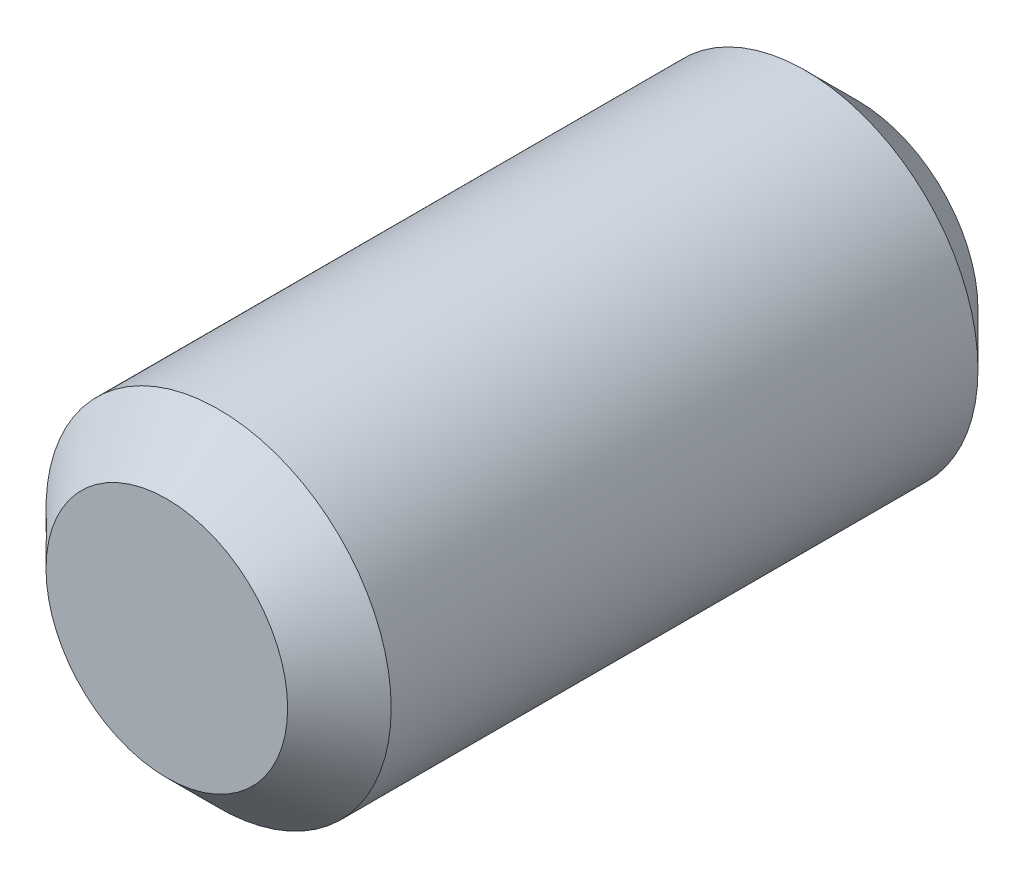
from build123d import *

# Parameters (mm, degrees)
SKETCH1_R           = 1
BOSS_EXTRUDE1_DEPTH = 4
CHAMFER1_SIZE       = 0.3


with BuildPart() as part:
    # Sketch1 → Boss-Extrude1 (new body)
    with BuildSketch(Plane.XY):
        Circle(SKETCH1_R)
    extrude(amount=BOSS_EXTRUDE1_DEPTH)

    # Chamfer1
    chamfer1_edges = [part.edges().sort_by_distance(p)[0] for p in [
        (-1, 0, 0),
        (-1, 0, 4),
    ]]
    chamfer(chamfer1_edges, length=CHAMFER1_SIZE)


solid = part.part
